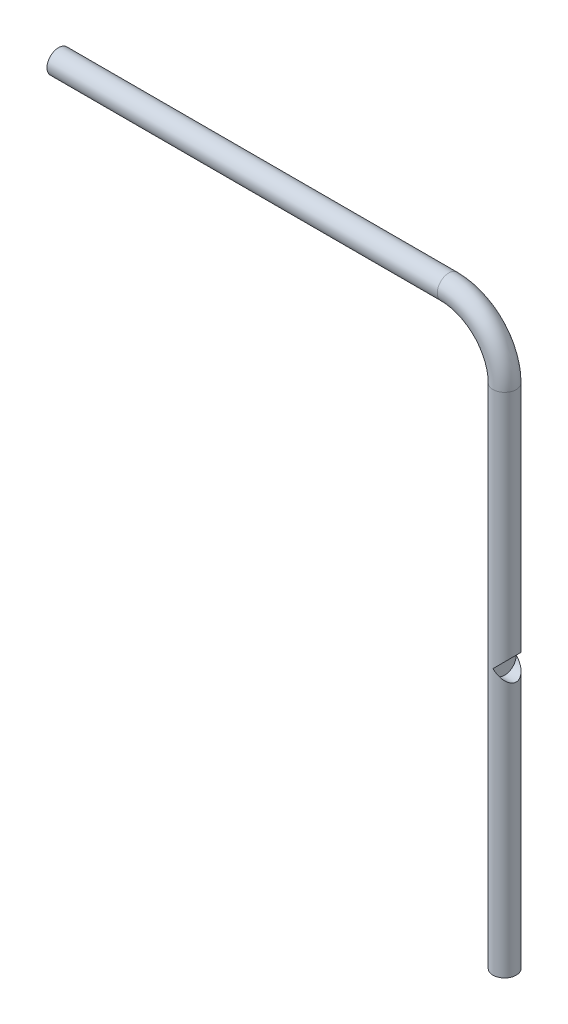
from build123d import *

# Parameters (mm, degrees)
SWEEP1_PROFILE_R    = 12.5
SKETCH2_R           = 12.5
BOSS_EXTRUDE4_DEPTH = 50.79
SKETCH11_R          = 12.5
CUT_EXTRUDE2_DEPTH  = 50.79


with BuildPart() as part:
    # Sweep1: sweep along a path in Sketch1
    with BuildLine(Plane.XY) as sweep1_path:
        Line((0, 0), (0, 495))
        ThreePointArc((0, 495), (-17.573593129, 537.426406871), (-60, 555))
        Line((-60, 555), (-480, 555))
    # Sweep1 profile (on start of the path) → Sweep1 (sweep)
    with BuildSketch(Plane.ZX):
        Circle(SWEEP1_PROFILE_R)
    sweep(path=sweep1_path.line)

    # Sketch2 → Boss-Extrude4 (add)
    with BuildSketch(Plane.XZ):
        Circle(SKETCH2_R)
    extrude(amount=BOSS_EXTRUDE4_DEPTH)

    # Sketch11 → Cut-Extrude2 (cut)
    with BuildSketch(Plane(origin=(0, 0, 0), x_dir=(0, 0, -1), z_dir=(1, 0, 0))):
        with Locations((0, 235)):
            Circle(SKETCH11_R)
    extrude(amount=CUT_EXTRUDE2_DEPTH, mode=Mode.SUBTRACT)


solid = part.part
